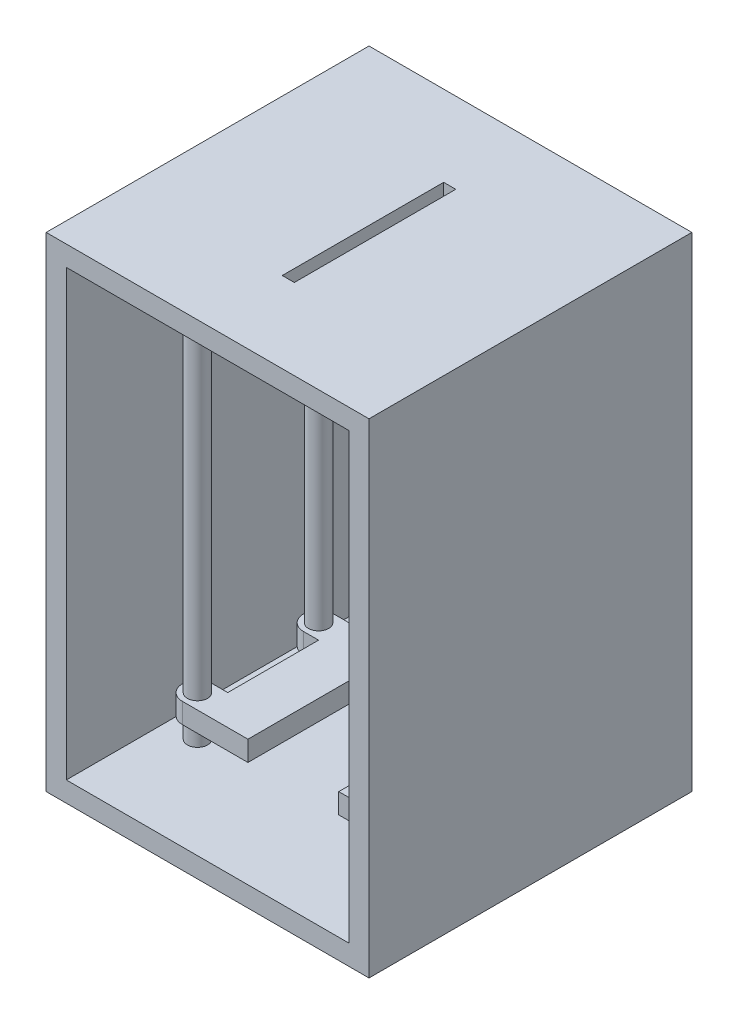
from build123d import *

# Parameters (mm, degrees)
SKETCH1_W           = 203.2
SKETCH1_H           = 304.8
BOSS_EXTRUDE1_DEPTH = 203.2
SKETCH2_W           = 177.8
SKETCH2_H           = 279.4
CUT_EXTRUDE1_DEPTH  = 190.5
SKETCH3_W           = 7.62
SKETCH3_H           = 101.6
CUT_EXTRUDE2_DEPTH  = 190.5
SKETCH4_R           = 6.35
BOSS_EXTRUDE2_DEPTH = 279.4
BOSS_EXTRUDE3_DEPTH = 25.4
CUT_EXTRUDE3_DEPTH  = 12.7
SKETCH4_2_R         = 6.35
BOSS_EXTRUDE5_DEPTH = 12.7


with BuildPart() as part:
    # Sketch1 → Boss-Extrude1 (new body)
    with BuildSketch(Plane.XY):
        Rectangle(SKETCH1_W, SKETCH1_H)
    extrude(amount=BOSS_EXTRUDE1_DEPTH)

    # Sketch2 → Cut-Extrude1 (cut)
    with BuildSketch(Plane.XY.offset(203.2)):
        Rectangle(SKETCH2_W, SKETCH2_H)
    extrude(amount=-CUT_EXTRUDE1_DEPTH, mode=Mode.SUBTRACT)

    # Sketch3 → Cut-Extrude2 (cut)
    with BuildSketch(Plane(origin=(0, 152.4, 0), x_dir=(1, 0, 0), z_dir=(0, 1, 0))):
        with Locations((0, -101.6)):
            Rectangle(SKETCH3_W, SKETCH3_H)
    extrude(amount=-CUT_EXTRUDE2_DEPTH, mode=Mode.SUBTRACT)

    # Sketch4 → Boss-Extrude2 (add)
    with BuildSketch(Plane(origin=(0, -139.7, 0), x_dir=(1, 0, 0), z_dir=(0, 1, 0))):
        with Locations((-69.85, -63.5)):
            Circle(SKETCH4_R)
        with Locations((69.85, -63.5)):
            Circle(SKETCH4_R)
        with Locations((69.85, -139.7)):
            Circle(SKETCH4_R)
        with Locations((-69.85, -139.7)):
            Circle(SKETCH4_R)
    extrude(amount=BOSS_EXTRUDE2_DEPTH)

    # Sketch7 → Boss-Extrude3 (add)
    with BuildSketch(Plane(origin=(0, -139.7, 0), x_dir=(1, 0, 0), z_dir=(0, 1, 0))):
        with BuildLine():
            Line((-69.85, -53.975), (-60.325, -53.975))
            Line((-60.325, -53.975), (-28.575, -53.975))
            Line((-28.575, -53.975), (-28.575, -149.225))
            Line((-28.575, -149.225), (-60.325, -149.225))
            Line((-60.325, -149.225), (-69.85, -149.225))
            ThreePointArc((-69.85, -149.225), (-79.375, -139.7), (-69.85, -130.175))
            Line((-69.85, -130.175), (-60.325, -130.175))
            Line((-60.325, -130.175), (-60.325, -73.025))
            Line((-60.325, -73.025), (-69.85, -73.025))
            ThreePointArc((-69.85, -73.025), (-79.375, -63.5), (-69.85, -53.975))
        make_face()
        with BuildLine():
            Line((60.325, -53.975), (28.575, -53.975))
            Line((28.575, -53.975), (28.575, -149.225))
            Line((28.575, -149.225), (60.325, -149.225))
            Line((60.325, -149.225), (69.85, -149.225))
            ThreePointArc((69.85, -149.225), (79.375, -139.7), (69.85, -130.175))
            Line((69.85, -130.175), (60.325, -130.175))
            Line((60.325, -130.175), (60.325, -73.025))
            Line((60.325, -73.025), (69.85, -73.025))
            ThreePointArc((69.85, -73.025), (79.375, -63.5), (69.85, -53.975))
            Line((69.85, -53.975), (60.325, -53.975))
        make_face()
    extrude(amount=BOSS_EXTRUDE3_DEPTH)

    # Sketch7_4 → Cut-Extrude3 (cut)
    with BuildSketch(Plane(origin=(0, -139.7, 0), x_dir=(1, 0, 0), z_dir=(0, 1, 0))):
        with BuildLine():
            Line((-69.85, -53.975), (-60.325, -53.975))
            Line((-60.325, -53.975), (-28.575, -53.975))
            Line((-28.575, -53.975), (-28.575, -149.225))
            Line((-28.575, -149.225), (-60.325, -149.225))
            Line((-60.325, -149.225), (-69.85, -149.225))
            ThreePointArc((-69.85, -149.225), (-79.375, -139.7), (-69.85, -130.175))
            Line((-69.85, -130.175), (-60.325, -130.175))
            Line((-60.325, -130.175), (-60.325, -73.025))
            Line((-60.325, -73.025), (-69.85, -73.025))
            ThreePointArc((-69.85, -73.025), (-79.375, -63.5), (-69.85, -53.975))
        make_face()
        with BuildLine():
            Line((60.325, -53.975), (28.575, -53.975))
            Line((28.575, -53.975), (28.575, -149.225))
            Line((28.575, -149.225), (60.325, -149.225))
            Line((60.325, -149.225), (69.85, -149.225))
            ThreePointArc((69.85, -149.225), (79.375, -139.7), (69.85, -130.175))
            Line((69.85, -130.175), (60.325, -130.175))
            Line((60.325, -130.175), (60.325, -73.025))
            Line((60.325, -73.025), (69.85, -73.025))
            ThreePointArc((69.85, -73.025), (79.375, -63.5), (69.85, -53.975))
            Line((69.85, -53.975), (60.325, -53.975))
        make_face()
    extrude(amount=CUT_EXTRUDE3_DEPTH, mode=Mode.SUBTRACT)

    # Sketch4_2 → Boss-Extrude5 (add)
    with BuildSketch(Plane(origin=(0, -139.7, 0), x_dir=(1, 0, 0), z_dir=(0, 1, 0))):
        with Locations((-69.85, -63.5)):
            Circle(SKETCH4_2_R)
        with Locations((69.85, -63.5)):
            Circle(SKETCH4_2_R)
        with Locations((69.85, -139.7)):
            Circle(SKETCH4_2_R)
        with Locations((-69.85, -139.7)):
            Circle(SKETCH4_2_R)
    extrude(amount=BOSS_EXTRUDE5_DEPTH)


solid = part.part
